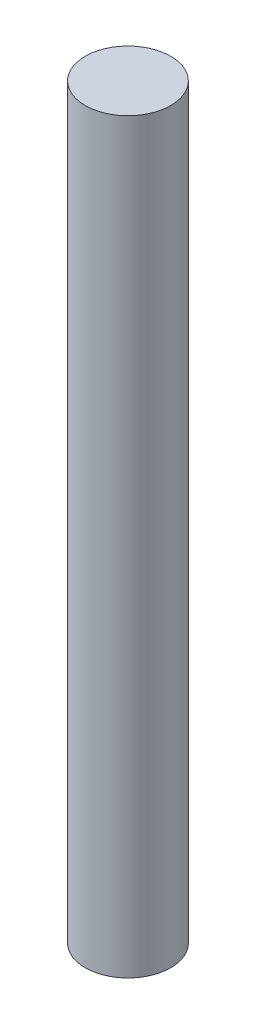
from build123d import *

# Parameters (mm, degrees)
SKETCH1_R           = 2.5
BOSS_EXTRUDE1_DEPTH = 43.7


with BuildPart() as part:
    # Sketch1 → Boss-Extrude1 (new body)
    with BuildSketch(Plane(origin=(0, 0, 0), x_dir=(1, 0, 0), z_dir=(0, 1, 0))):
        Circle(SKETCH1_R)
    extrude(amount=BOSS_EXTRUDE1_DEPTH)


solid = part.part
